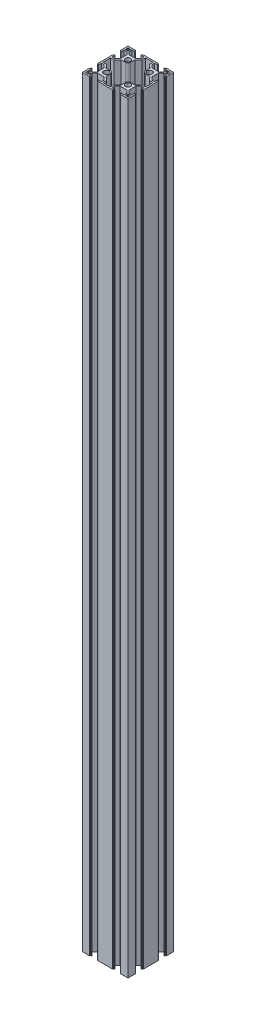
from build123d import *

# Parameters (mm, degrees)
SKETCH1_W                = 60
SKETCH1_H                = 60
BOSS_EXTRUDE1_DEPTH      = 1000
CUT_EXTRUDE1_DEPTH       = 1001.899595364
CIRPATTERN1_COUNT        = 4
CIRPATTERN1_COPY_1_DEPTH = 1001.899595364
CIRPATTERN1_COPY_2_DEPTH = 1001.899595364
CIRPATTERN1_COPY_3_DEPTH = 1001.899595364
SKETCH4_R                = 3.4
CUT_EXTRUDE2_DEPTH       = 1000
FILLET1_R                = 0.2
FILLET2_R                = 0.2
FILLET3_R                = 0.2
FILLET4_R                = 0.2


with BuildPart() as part:
    # Sketch1 → Boss-Extrude1 (new body)
    with BuildSketch(Plane(origin=(0, 0, 0), x_dir=(1, 0, 0), z_dir=(0, 1, 0))):
        Rectangle(SKETCH1_W, SKETCH1_H)
        Polygon((-23.05, -28), (-6.95, -28), (-6.95, -24.4), (-10.615, -20.8), (-19.385, -20.8), (-23.05, -24.4), align=None, mode=Mode.SUBTRACT)
        Polygon((10.615, -20.8), (19.385, -20.8), (23.05, -24.4), (23.05, -28), (6.95, -28), (6.95, -24.4), align=None, mode=Mode.SUBTRACT)
        Polygon((19.385, 20.8), (23.05, 24.4), (23.05, 28), (6.95, 28), (6.95, 24.4), (10.615, 20.8), align=None, mode=Mode.SUBTRACT)
        Polygon((-23.05, 24.4), (-23.05, 28), (-6.95, 28), (-6.95, 24.4), (-10.615, 20.8), (-19.385, 20.8), align=None, mode=Mode.SUBTRACT)
        Polygon((-20.8, 19.385), (-24.4, 23.05), (-28, 23.05), (-28, 6.95), (-24.4, 6.95), (-20.8, 10.615), align=None, mode=Mode.SUBTRACT)
        Polygon((-24.4, -23.05), (-28, -23.05), (-28, -6.95), (-24.4, -6.95), (-20.8, -10.615), (-20.8, -19.385), align=None, mode=Mode.SUBTRACT)
        Polygon((20.8, -19.385), (24.4, -23.05), (28, -23.05), (28, -6.95), (24.4, -6.95), (20.8, -10.615), align=None, mode=Mode.SUBTRACT)
        Polygon((24.4, 23.05), (28, 23.05), (28, 6.95), (24.4, 6.95), (20.8, 10.615), (20.8, 19.385), align=None, mode=Mode.SUBTRACT)
    extrude(amount=BOSS_EXTRUDE1_DEPTH)

    # Sketch2 → Cut-Extrude1 (cut, through all)
    with BuildSketch(Plane(origin=(0, 1000, 0), x_dir=(1, 0, 0), z_dir=(0, 1, 0))):
        Polygon((-19.1, -28), (-19.1, -29), (-20.1, -29), (-20.1, -30), (-9.9, -30), (-9.9, -29), (-10.9, -29), (-10.9, -28), align=None)
    cut_extrude1 = extrude(amount=-CUT_EXTRUDE1_DEPTH, mode=Mode.SUBTRACT)

    # Mirror1: Cut-Extrude1 across plane
    add(cut_extrude1.mirror(Plane(origin=(0, 0, 0), x_dir=(0, 0, 1), z_dir=(1, 0, 0))), mode=Mode.SUBTRACT)

    # CirPattern1: Cut-Extrude1 ×4 about axis
    cirpattern1_axis = Axis((0, 1050, 0), (0, -1, 0))
    for i in range(1, CIRPATTERN1_COUNT):
        add(cut_extrude1.rotate(cirpattern1_axis, i * 360 / CIRPATTERN1_COUNT), mode=Mode.SUBTRACT)

    # CirPattern1 copy 1 sketch → CirPattern1 copy 1 (cut, through all)
    with BuildSketch(Plane(origin=(0, 1000, 0), x_dir=(0, 0, -1), z_dir=(0, 1, 0))):
        Polygon((-19.1, 28), (-19.1, 29), (-20.1, 29), (-20.1, 30), (-9.9, 30), (-9.9, 29), (-10.9, 29), (-10.9, 28), align=None)
    extrude(amount=-CIRPATTERN1_COPY_1_DEPTH, mode=Mode.SUBTRACT)

    # CirPattern1 copy 2 sketch → CirPattern1 copy 2 (cut, through all)
    with BuildSketch(Plane(origin=(0, 1000, 0), x_dir=(1, 0, 0), z_dir=(0, 1, 0))):
        Polygon((-19.1, 28), (-19.1, 29), (-20.1, 29), (-20.1, 30), (-9.9, 30), (-9.9, 29), (-10.9, 29), (-10.9, 28), align=None)
    extrude(amount=-CIRPATTERN1_COPY_2_DEPTH, mode=Mode.SUBTRACT)

    # CirPattern1 copy 3 sketch → CirPattern1 copy 3 (cut, through all)
    with BuildSketch(Plane.ZX.offset(1000)):
        Polygon((-19.1, 28), (-19.1, 29), (-20.1, 29), (-20.1, 30), (-9.9, 30), (-9.9, 29), (-10.9, 29), (-10.9, 28), align=None)
    extrude(amount=-CIRPATTERN1_COPY_3_DEPTH, mode=Mode.SUBTRACT)

    # Sketch4 → Cut-Extrude2 (cut)
    with BuildSketch(Plane(origin=(0, 1000, 0), x_dir=(1, 0, 0), z_dir=(0, 1, 0))):
        with BuildLine():
            Line((-13.197035349, 9.797035349), (-18.8, 9.797035349))
            Line((-18.8, 9.797035349), (-23.561071557, 4.95))
            Line((-23.561071557, 4.95), (-28, 4.95))
            Line((-28, 4.95), (-28, -4.95))
            Line((-28, -4.95), (-23.561071557, -4.95))
            Line((-23.561071557, -4.95), (-18.8, -9.797035349))
            Line((-18.8, -9.797035349), (-13.197035349, -9.797035349))
            ThreePointArc((-13.197035349, -9.797035349), (-10.792872293, -10.792872293), (-9.797035349, -13.197035349))
            Line((-9.797035349, -13.197035349), (-9.797035349, -18.8))
            Line((-9.797035349, -18.8), (-4.95, -23.561071557))
            Line((-4.95, -23.561071557), (-4.95, -28))
            Line((-4.95, -28), (4.95, -28))
            Line((4.95, -28), (4.95, -23.561071557))
            Line((4.95, -23.561071557), (9.797035349, -18.8))
            Line((9.797035349, -18.8), (9.797035349, -13.197035349))
            ThreePointArc((9.797035349, -13.197035349), (10.792872293, -10.792872293), (13.197035349, -9.797035349))
            Line((13.197035349, -9.797035349), (18.8, -9.797035349))
            Line((18.8, -9.797035349), (23.561071557, -4.95))
            Line((23.561071557, -4.95), (28, -4.95))
            Line((28, -4.95), (28, 4.95))
            Line((28, 4.95), (23.561071557, 4.95))
            Line((23.561071557, 4.95), (18.8, 9.797035349))
            Line((18.8, 9.797035349), (13.197035349, 9.797035349))
            ThreePointArc((13.197035349, 9.797035349), (10.792872293, 10.792872293), (9.797035349, 13.197035349))
            Line((9.797035349, 13.197035349), (9.797035349, 18.8))
            Line((9.797035349, 18.8), (4.95, 23.561071557))
            Line((4.95, 23.561071557), (4.95, 28))
            Line((4.95, 28), (-4.95, 28))
            Line((-4.95, 28), (-4.95, 23.561071557))
            Line((-4.95, 23.561071557), (-9.797035349, 18.8))
            Line((-9.797035349, 18.8), (-9.797035349, 13.197035349))
            ThreePointArc((-9.797035349, 13.197035349), (-10.792872293, 10.792872293), (-13.197035349, 9.797035349))
        make_face()
        with BuildLine():
            ThreePointArc((-28, -27.5), (-27.853553391, -27.853553391), (-27.5, -28))
            Line((-27.5, -28), (-24.9, -28))
            ThreePointArc((-24.9, -28), (-24.546446609, -27.853553391), (-24.4, -27.5))
            Line((-24.4, -27.5), (-24.4, -24.9))
            ThreePointArc((-24.4, -24.9), (-24.546446609, -24.546446609), (-24.9, -24.4))
            Line((-24.9, -24.4), (-27.5, -24.4))
            ThreePointArc((-27.5, -24.4), (-27.853553391, -24.546446609), (-28, -24.9))
            Line((-28, -24.9), (-28, -27.5))
        make_face()
        with BuildLine():
            ThreePointArc((24.4, -27.5), (24.546446609, -27.853553391), (24.9, -28))
            Line((24.9, -28), (27.5, -28))
            ThreePointArc((27.5, -28), (27.853553391, -27.853553391), (28, -27.5))
            Line((28, -27.5), (28, -24.9))
            ThreePointArc((28, -24.9), (27.853553391, -24.546446609), (27.5, -24.4))
            Line((27.5, -24.4), (24.9, -24.4))
            ThreePointArc((24.9, -24.4), (24.546446609, -24.546446609), (24.4, -24.9))
            Line((24.4, -24.9), (24.4, -27.5))
        make_face()
        with BuildLine():
            ThreePointArc((-27.5, 28), (-27.853553391, 27.853553391), (-28, 27.5))
            Line((-28, 27.5), (-28, 24.9))
            ThreePointArc((-28, 24.9), (-27.853553391, 24.546446609), (-27.5, 24.4))
            Line((-27.5, 24.4), (-24.9, 24.4))
            ThreePointArc((-24.9, 24.4), (-24.546446609, 24.546446609), (-24.4, 24.9))
            Line((-24.4, 24.9), (-24.4, 27.5))
            ThreePointArc((-24.4, 27.5), (-24.546446609, 27.853553391), (-24.9, 28))
            Line((-24.9, 28), (-27.5, 28))
        make_face()
        with BuildLine():
            ThreePointArc((28, 27.5), (27.853553391, 27.853553391), (27.5, 28))
            Line((27.5, 28), (24.9, 28))
            ThreePointArc((24.9, 28), (24.546446609, 27.853553391), (24.4, 27.5))
            Line((24.4, 27.5), (24.4, 24.9))
            ThreePointArc((24.4, 24.9), (24.546446609, 24.546446609), (24.9, 24.4))
            Line((24.9, 24.4), (27.5, 24.4))
            ThreePointArc((27.5, 24.4), (27.853553391, 24.546446609), (28, 24.9))
            Line((28, 24.9), (28, 27.5))
        make_face()
        with Locations((14.298517674, 14.298517674)):
            Circle(SKETCH4_R)
        with Locations((14.298517674, -14.298517674)):
            Circle(SKETCH4_R)
        with Locations((-14.298517674, -14.298517674)):
            Circle(SKETCH4_R)
        with Locations((-14.298517674, 14.298517674)):
            Circle(SKETCH4_R)
    extrude(amount=-CUT_EXTRUDE2_DEPTH, mode=Mode.SUBTRACT)

    # Fillet1
    fillet1_edges = [part.edges().sort_by_distance(p)[0] for p in [
        (28, 500, -19.1),
        (30, 500, -20.1),
        (29, 500, -20.1),
        (29, 500, -19.1),
        (28, 500, 10.9),
        (29, 500, 9.9),
        (28, 500, 19.1),
        (29, 500, 20.1),
        (30, 500, 20.1),
        (29, 500, 19.1),
        (29, 500, 10.9),
        (30, 500, 9.9),
        (30, 500, -9.9),
        (29, 500, -9.9),
        (29, 500, -10.9),
        (28, 500, -10.9),
    ]]
    fillet(fillet1_edges, radius=FILLET1_R)

    # Fillet2
    fillet2_edges = [part.edges().sort_by_distance(p)[0] for p in [
        (-20.1, 0, -29.5),
        (-20.1, 1000, -29.5),
        (-20.1, 500, -29),
        (-19.6, 0, -29),
        (-19.1, 500, -29),
        (-19.6, 1000, -29),
        (-9.9, 500, -30),
        (-10.9, 500, -28),
        (-10.9, 500, -29),
        (-9.9, 500, -29),
        (19.1, 500, -28),
        (19.1, 500, -29),
        (20.1, 500, -29),
        (20.1, 500, -30),
        (10.9, 500, -28),
        (10.9, 500, -29),
        (9.9, 500, -29),
        (9.9, 500, -30),
        (-19.1, 500, -28),
        (-20.1, 500, -30),
    ]]
    fillet(fillet2_edges, radius=FILLET2_R)

    # Fillet3
    fillet3_edges = [part.edges().sort_by_distance(p)[0] for p in [
        (-29, 500, 9.9),
        (-29, 500, -20.1),
        (-30, 500, -20.1),
        (-29, 500, -19.1),
        (-28, 500, -10.9),
        (-29, 500, -10.9),
        (-29, 500, -9.9),
        (-30, 500, -9.9),
        (-29, 500, 10.9),
        (-30, 500, 9.9),
        (-28, 500, 19.1),
        (-29, 500, 19.1),
        (-29, 500, 20.1),
        (-30, 500, 20.1),
    ]]
    fillet(fillet3_edges, radius=FILLET3_R)

    # Fillet4
    fillet4_edges = [part.edges().sort_by_distance(p)[0] for p in [
        (-19.1, 500, 28),
        (10.9, 500, 28),
        (19.1, 500, 28),
        (20.1, 500, 29),
        (-10.9, 500, 28),
        (-9.9, 500, 29),
        (9.9, 500, 29),
        (-20.1, 500, 29),
        (19.1, 500, 29),
        (20.1, 500, 30),
        (10.9, 500, 29),
        (9.9, 500, 30),
        (-9.9, 500, 30),
        (-10.9, 500, 29),
        (-19.1, 500, 29),
        (-20.1, 500, 30),
    ]]
    fillet(fillet4_edges, radius=FILLET4_R)


solid = part.part
